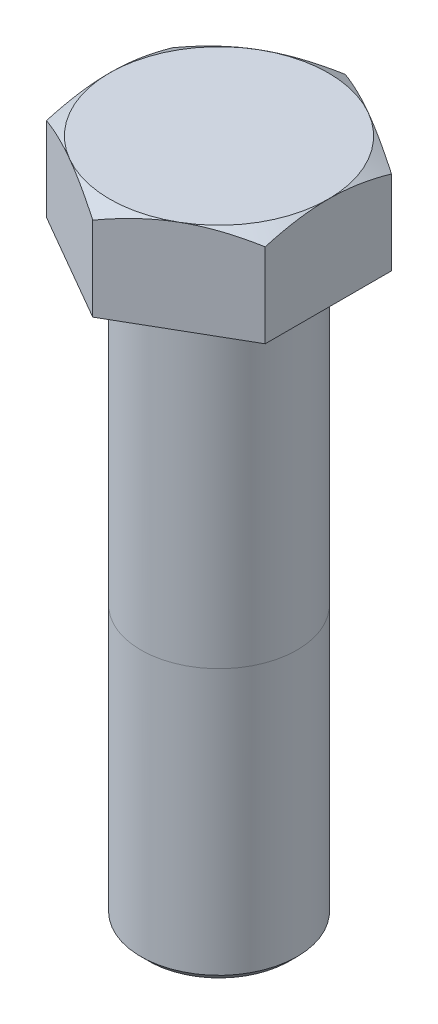
from build123d import *

# Parameters (mm, degrees)
BOSS_EXTRUDE1_DEPTH = 12
SKETCH2_OUTSIDE_W   = 80.454
SKETCH2_OUTSIDE_H   = 84.786
SKETCH2_OUTSIDE_R   = 14
CUT_EXTRUDE1_DEPTH  = 12
CUT_EXTRUDE1_TAPER  = 60
SKETCH3_R           = 10
BOSS_EXTRUDE2_DEPTH = 75
CHAMFER1_SIZE       = 1


with BuildPart() as part:
    # Sketch1 → Boss-Extrude1 (new body)
    with BuildSketch(Plane(origin=(0, 0, 0), x_dir=(1, 0, 0), z_dir=(0, 1, 0))):
        Polygon((0, -16.165807537), (14, -8.082903769), (14, 8.082903769), (0, 16.165807537), (-14, 8.082903769), (-14, -8.082903769), align=None)
    extrude(amount=BOSS_EXTRUDE1_DEPTH)

    # Sketch2 outside → Cut-Extrude1 (cut)
    with BuildSketch(Plane(origin=(0, 12, 0), x_dir=(1, 0, 0), z_dir=(0, 1, 0))):
        Rectangle(SKETCH2_OUTSIDE_W, SKETCH2_OUTSIDE_H)
        Circle(SKETCH2_OUTSIDE_R, mode=Mode.SUBTRACT)
    extrude(amount=-CUT_EXTRUDE1_DEPTH, taper=CUT_EXTRUDE1_TAPER, mode=Mode.SUBTRACT)

    # Sketch3 → Boss-Extrude2 (add)
    with BuildSketch(Plane.XZ):
        Circle(SKETCH3_R)
    extrude(amount=BOSS_EXTRUDE2_DEPTH)

    # Chamfer1
    chamfer1_edges = [part.edges().sort_by_distance(p)[0] for p in [
        (-10, -75, 0),
    ]]
    chamfer(chamfer1_edges, length=CHAMFER1_SIZE)


solid = part.part
